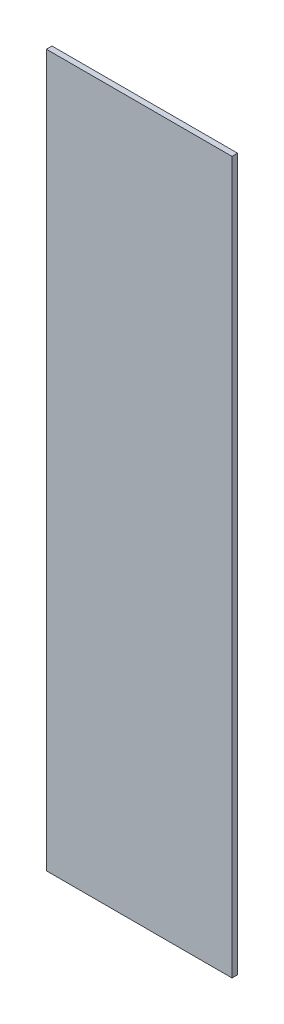
from build123d import *

# Parameters (mm, degrees)
SKETCH_1_W      = 600
SKETCH_1_H      = 2300
EXTRUDE_1_DEPTH = 18


with BuildPart() as part:
    # Эскиз1 → Бобышка-Вытянуть1 (new body)
    with BuildSketch(Plane.XY):
        with Locations((300, 1150)):
            Rectangle(SKETCH_1_W, SKETCH_1_H)
    extrude(amount=EXTRUDE_1_DEPTH)


solid = part.part
